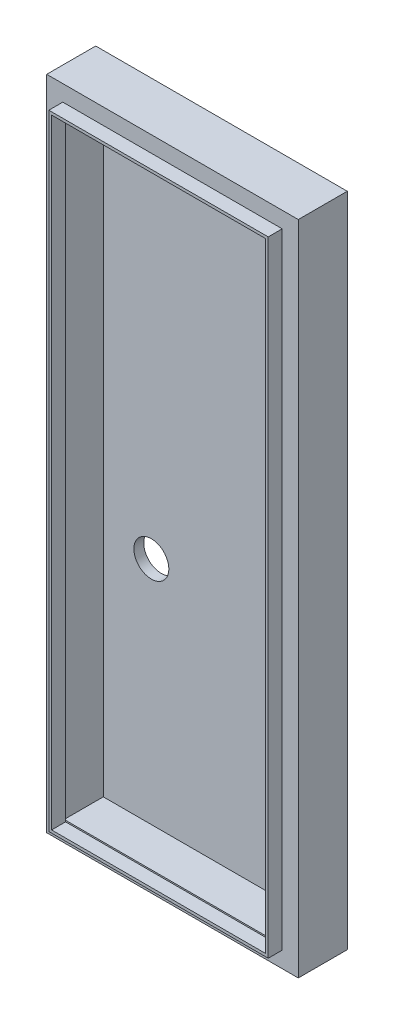
from build123d import *

# Parameters (mm, degrees)
SKETCH1_W                = 45.72
SKETCH1_H                = 119.38
BOSS_EXTRUDE1_DEPTH      = 1.27
BOSS_EXTRUDE1_DEPTH_BACK = 7.636822689
SKETCH2_W                = 39.878
SKETCH2_H                = 113.538
SKETCH2_W_2              = 38.862
SKETCH2_H_2              = 112.522
BOSS_EXTRUDE2_DEPTH      = 2.54
SKETCH4_R                = 3.175
CUT_EXTRUDE1_DEPTH       = 12.446822689
SKETCH12_W               = 39.37
SKETCH12_H               = 112.522
CUT_EXTRUDE3_DEPTH       = 7.112


with BuildPart() as part:
    # Sketch1 → Boss-Extrude1 (new body, two sides)
    with BuildSketch(Plane.XY) as boss_extrude1_sk:
        with Locations((-64.545156171, 15.983606897)):
            Rectangle(SKETCH1_W, SKETCH1_H)
    extrude(amount=BOSS_EXTRUDE1_DEPTH)
    extrude(boss_extrude1_sk.sketch, amount=-BOSS_EXTRUDE1_DEPTH_BACK)

    # Sketch2 → Boss-Extrude2 (add)
    with BuildSketch(Plane.XY.offset(1.27)):
        with Locations((-64.545156171, 15.983606897)):
            Rectangle(SKETCH2_W, SKETCH2_H)
        with Locations((-64.545156171, 15.983606897)):
            Rectangle(SKETCH2_W_2, SKETCH2_H_2, mode=Mode.SUBTRACT)
    extrude(amount=BOSS_EXTRUDE2_DEPTH)

    # Sketch4 → Cut-Extrude1 (cut, through all)
    with BuildSketch(Plane(origin=(0, 0, -7.636822689), x_dir=(-1, 0, 0), z_dir=(0, 0, -1))):
        with Locations((75.500176171, 1.792626897)):
            Circle(SKETCH4_R)
    extrude(amount=-CUT_EXTRUDE1_DEPTH, mode=Mode.SUBTRACT)

    # Sketch12 → Cut-Extrude3 (cut)
    with BuildSketch(Plane.XY.offset(1.27)):
        with Locations((-64.545156171, 16.237606897)):
            Rectangle(SKETCH12_W, SKETCH12_H)
    extrude(amount=-CUT_EXTRUDE3_DEPTH, mode=Mode.SUBTRACT)


solid = part.part
